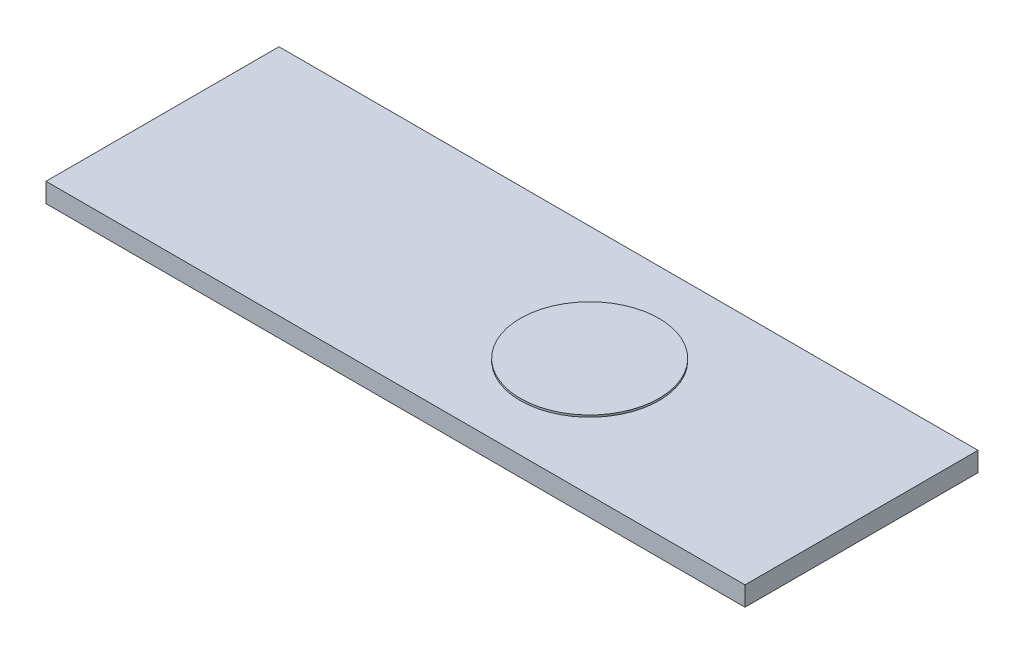
from build123d import *

# Parameters (mm, degrees)
SKETCH1_W = 36
SKETCH1_H = 12
SPE_DEPTH = 1
SKETCH2_R = 3.571930641
WE_DEPTH  = 0.1


with BuildPart() as part:
    # Sketch1 → SPE (new body)
    with BuildSketch(Plane(origin=(0, 0, 0), x_dir=(1, 0, 0), z_dir=(0, 1, 0))):
        Rectangle(SKETCH1_W, SKETCH1_H)
    extrude(amount=SPE_DEPTH)

    # Sketch2 → WE (add)
    with BuildSketch(Plane(origin=(0, 1, 0), x_dir=(1, 0, 0), z_dir=(0, 1, 0))):
        with Locations((4, 0)):
            Circle(SKETCH2_R)
    extrude(amount=WE_DEPTH)


solid = part.part
